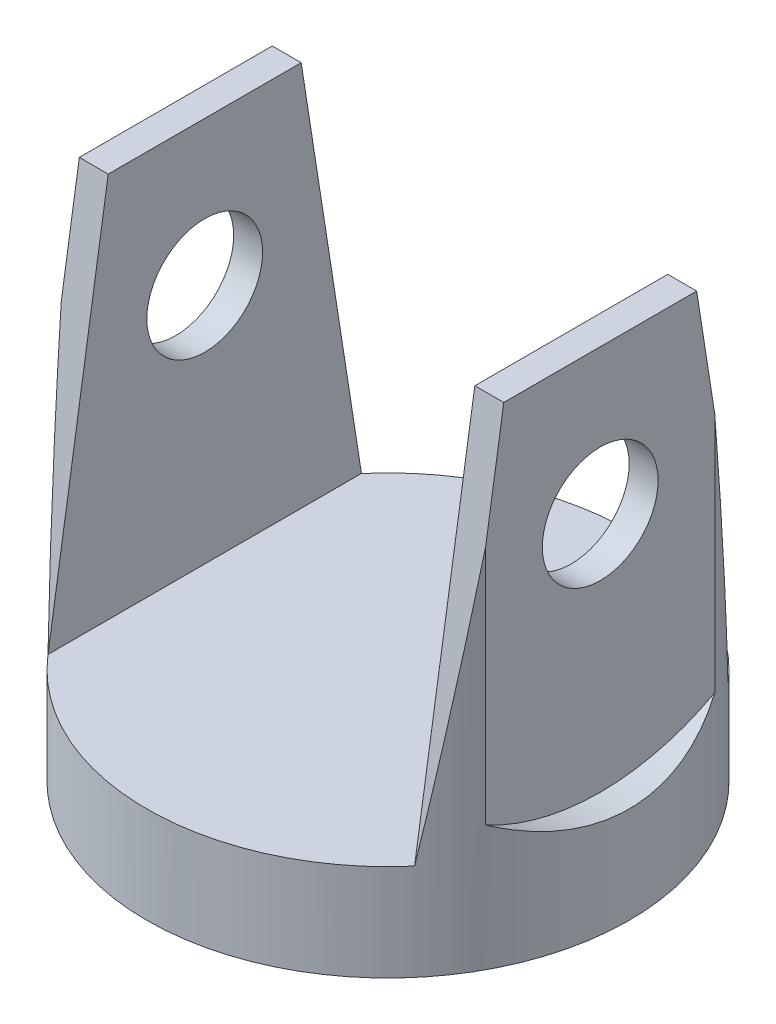
from build123d import *

# Parameters (mm, degrees)
SKETCH1_R               = 125
BOSS_EXTRUDE1_DEPTH     = 250
SKETCH3_W               = 190
SKETCH3_H               = 250
CUT_EXTRUDE1_DEPTH      = 200
CUT_EXTRUDE3_DEPTH      = 221
CUT_EXTRUDE3_DEPTH_BACK = 31
SKETCH8_R               = 30
CUT_EXTRUDE4_DEPTH      = 221
CUT_EXTRUDE4_DEPTH_BACK = 31
SKETCH6_R               = 125
CUT_EXTRUDE8_DEPTH      = 60
SKETCH7_R               = 125
CUT_EXTRUDE9_DEPTH      = 60
SKETCH9_R               = 59.95
BOSS_EXTRUDE2_DEPTH     = 20


with BuildPart() as part:
    # Sketch1 → Boss-Extrude1 (new body)
    with BuildSketch(Plane(origin=(0, 0, 0), x_dir=(1, 0, 0), z_dir=(0, 1, 0))):
        Circle(SKETCH1_R)
    extrude(amount=BOSS_EXTRUDE1_DEPTH)

    # Sketch3 → Cut-Extrude1 (cut)
    with BuildSketch(Plane(origin=(0, 250, 0), x_dir=(1, 0, 0), z_dir=(0, 1, 0))):
        Rectangle(SKETCH3_W, SKETCH3_H)
    extrude(amount=-CUT_EXTRUDE1_DEPTH, mode=Mode.SUBTRACT)

    # Sketch4 → Cut-Extrude3 (cut, two sides)
    with BuildSketch(Plane(origin=(-95, 0, 0), x_dir=(0, 0, -1), z_dir=(1, 0, 0))) as cut_extrude3_sk:
        Polygon((-81.240384046, 250), (-81.240384046, 50), (-50, 250), align=None)
        Polygon((50, 250), (81.240384046, 50), (81.240384046, 250), align=None)
    extrude(amount=CUT_EXTRUDE3_DEPTH, mode=Mode.SUBTRACT)
    extrude(cut_extrude3_sk.sketch, amount=-CUT_EXTRUDE3_DEPTH_BACK, mode=Mode.SUBTRACT)

    # Sketch8 → Cut-Extrude4 (cut, two sides)
    with BuildSketch(Plane(origin=(-95, 0, 0), x_dir=(0, 0, -1), z_dir=(1, 0, 0))) as cut_extrude4_sk:
        with Locations((0, 175)):
            Circle(SKETCH8_R)
    extrude(amount=CUT_EXTRUDE4_DEPTH, mode=Mode.SUBTRACT)
    extrude(cut_extrude4_sk.sketch, amount=-CUT_EXTRUDE4_DEPTH_BACK, mode=Mode.SUBTRACT)

    # Sketch6 → Cut-Extrude8 (cut)
    with BuildSketch(Plane(origin=(-170, 0, 0), x_dir=(0, 0, -1), z_dir=(1, 0, 0))):
        with Locations((0, 175)):
            Circle(SKETCH6_R)
    extrude(amount=CUT_EXTRUDE8_DEPTH, mode=Mode.SUBTRACT)

    # Sketch7 → Cut-Extrude9 (cut)
    with BuildSketch(Plane.ZY.offset(-170)):
        with Locations((0, 175)):
            Circle(SKETCH7_R)
    extrude(amount=CUT_EXTRUDE9_DEPTH, mode=Mode.SUBTRACT)

    # Sketch9 → Boss-Extrude2 (add)
    with BuildSketch(Plane.XZ):
        Circle(SKETCH9_R)
    extrude(amount=BOSS_EXTRUDE2_DEPTH)


solid = part.part
